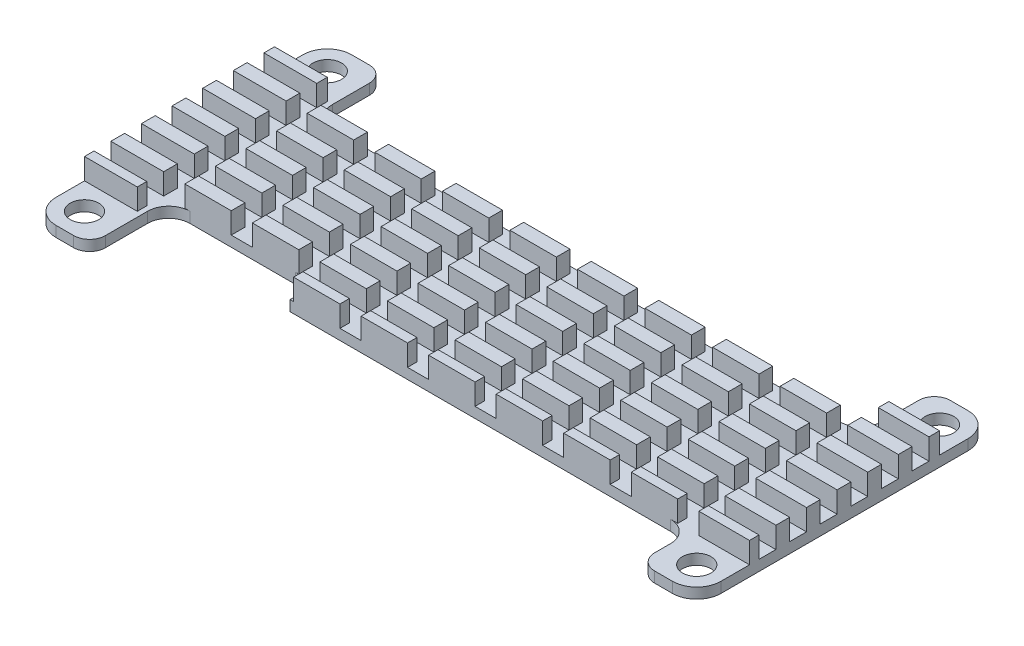
from build123d import *

# Parameters (mm, degrees)
SKETCH_1_R          = 1.35
EXTRUDE_1_DEPTH     = 3
FILLET_1_R          = 2.3
FILLET_2_R          = 1.5
SKETCH_2_W          = 14
SKETCH_2_H          = 2.5
CUT_EXTRUDE_1_DEPTH = 10
SKETCH_3_W          = 72.552827137
SKETCH_3_H          = 8.597527301
SKETCH_3_W_2        = 76.751188564
SKETCH_3_H_2        = 9.746182675
CUT_EXTRUDE_2_DEPTH = 2
FILLET_3_R          = 2
SKETCH_4_W          = 63
SKETCH_4_H          = 1.6
CUT_EXTRUDE_4_DEPTH = 2
SKETCH_5_W          = 2
SKETCH_5_H          = 18
CUT_EXTRUDE_5_DEPTH = 2


with BuildPart() as part:
    # 草图1 → 凸台-拉伸1 (new body)
    with BuildSketch(Plane(origin=(0, 0, 0), x_dir=(1, 0, 0), z_dir=(0, 1, 0))):
        Polygon((26.02, 14), (31.5, 14), (31.5, -14), (26.02, -14), (26.02, -9), (-26.02, -9), (-26.02, -14), (-31.5, -14), (-31.5, 14), (-26.02, 14), (-26.02, 7), (26.02, 7), align=None)
        with Locations((-29, 11.5)):
            Circle(SKETCH_1_R, mode=Mode.SUBTRACT)
        with Locations((29, 11.5)):
            Circle(SKETCH_1_R, mode=Mode.SUBTRACT)
        with Locations((29, -11.5)):
            Circle(SKETCH_1_R, mode=Mode.SUBTRACT)
        with Locations((-29, -11.5)):
            Circle(SKETCH_1_R, mode=Mode.SUBTRACT)
    extrude(amount=EXTRUDE_1_DEPTH)

    # 圆角1
    fillet_1_edges = [part.edges().sort_by_distance(p)[0] for p in [
        (-31.5, 1.5, 14),
        (-31.5, 1.5, -14),
        (31.5, 1.5, -14),
        (31.5, 1.5, 14),
    ]]
    fillet(fillet_1_edges, radius=FILLET_1_R)

    # 圆角2
    fillet_2_edges = [part.edges().sort_by_distance(p)[0] for p in [
        (26.02, 1.5, 14),
        (-26.02, 1.5, 14),
        (-26.02, 1.5, -14),
        (26.02, 1.5, -14),
    ]]
    fillet(fillet_2_edges, radius=FILLET_2_R)

    # 草图2 → 切除-拉伸1 (cut)
    with BuildSketch(Plane(origin=(0, 3, 0), x_dir=(1, 0, 0), z_dir=(0, 1, 0))):
        with Locations((-19.02, -7.75)):
            Rectangle(SKETCH_2_W, SKETCH_2_H)
    extrude(amount=-CUT_EXTRUDE_1_DEPTH, mode=Mode.SUBTRACT)

    # 草图3 → 切除-拉伸2 (cut)
    with BuildSketch(Plane(origin=(0, 3, 0), x_dir=(1, 0, 0), z_dir=(0, 1, 0))):
        with Locations((1.233568605, 13.29876365)):
            Rectangle(SKETCH_3_W, SKETCH_3_H)
        with Locations((-0.865612109, -13.873091338)):
            Rectangle(SKETCH_3_W_2, SKETCH_3_H_2)
    extrude(amount=-CUT_EXTRUDE_2_DEPTH, mode=Mode.SUBTRACT)

    # 圆角3
    fillet_3_edges = [part.edges().sort_by_distance(p)[0] for p in [
        (-12.02, 1.5, 6.5),
        (-26.02, 1.5, 6.5),
        (26.02, 0.5, 9),
        (-26.02, 1.5, -7),
        (26.02, 1.5, -7),
    ]]
    fillet(fillet_3_edges, radius=FILLET_3_R)

    # 草图4 → 切除-拉伸4 (cut)
    with BuildSketch(Plane(origin=(0, 3, 0), x_dir=(1, 0, 0), z_dir=(0, 1, 0))):
        with Locations((0, 7.2)):
            Rectangle(SKETCH_4_W, SKETCH_4_H)
        with Locations((0, 4.3)):
            Rectangle(SKETCH_4_W, SKETCH_4_H)
        with Locations((0, 1.4)):
            Rectangle(SKETCH_4_W, SKETCH_4_H)
        with Locations((0, -1.5)):
            Rectangle(SKETCH_4_W, SKETCH_4_H)
        with Locations((0, -4.4)):
            Rectangle(SKETCH_4_W, SKETCH_4_H)
        with Locations((0, -7.3)):
            Rectangle(SKETCH_4_W, SKETCH_4_H)
    extrude(amount=-CUT_EXTRUDE_4_DEPTH, mode=Mode.SUBTRACT)

    # 草图5 → 切除-拉伸5 (cut)
    with BuildSketch(Plane(origin=(0, 3, 0), x_dir=(1, 0, 0), z_dir=(0, 1, 0))):
        with Locations((-25.5, 0)):
            Rectangle(SKETCH_5_W, SKETCH_5_H)
        with Locations((-19.1, 0)):
            Rectangle(SKETCH_5_W, SKETCH_5_H)
        with Locations((-12.7, 0)):
            Rectangle(SKETCH_5_W, SKETCH_5_H)
        with Locations((-6.3, 0)):
            Rectangle(SKETCH_5_W, SKETCH_5_H)
        with Locations((0.1, 0)):
            Rectangle(SKETCH_5_W, SKETCH_5_H)
        with Locations((6.5, 0)):
            Rectangle(SKETCH_5_W, SKETCH_5_H)
        with Locations((12.9, 0)):
            Rectangle(SKETCH_5_W, SKETCH_5_H)
        with Locations((19.3, 0)):
            Rectangle(SKETCH_5_W, SKETCH_5_H)
        with Locations((25.7, 0)):
            Rectangle(SKETCH_5_W, SKETCH_5_H)
    extrude(amount=-CUT_EXTRUDE_5_DEPTH, mode=Mode.SUBTRACT)


solid = part.part
